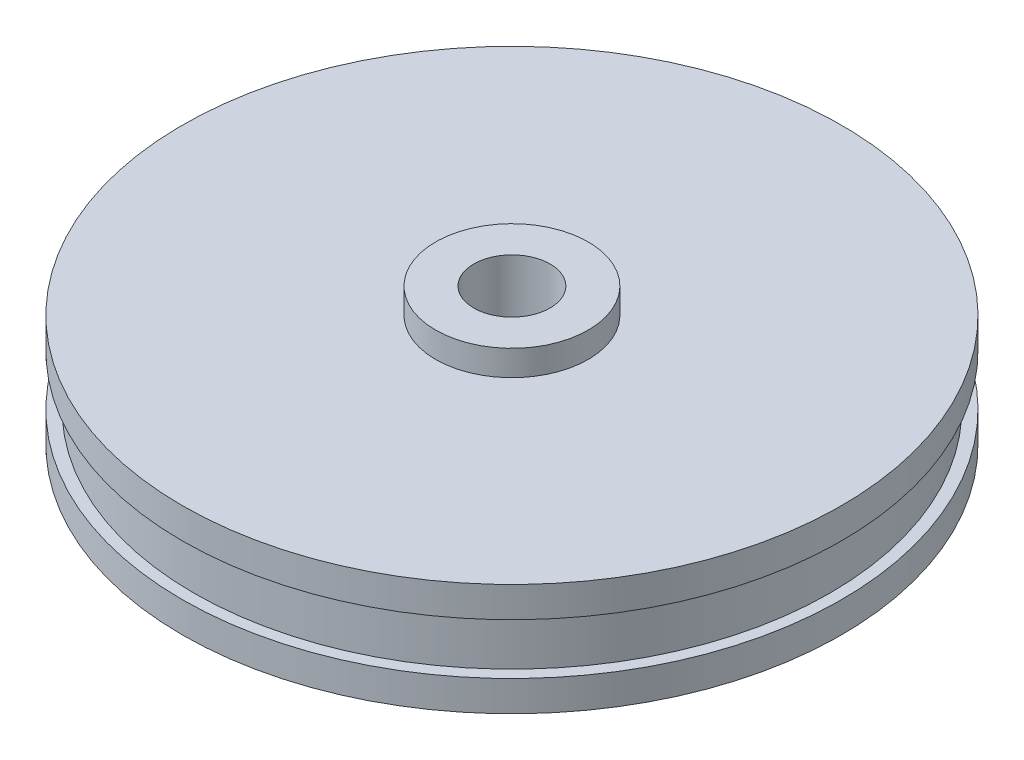
from build123d import *


with BuildPart() as part:
    # Esquisse1 → Révolution2 (revolve)
    with BuildSketch(Plane.XY):
        Polygon((12.95, -2.2), (1.5, -2.2), (1.5, 3.2), (3, 3.2), (3, 2.2), (12.95, 2.2), (12.95, 1), (12.5, 1), (12.5, -1), (12.95, -1), align=None)
    revolve(axis=Axis((0, 17.85, 0), (0, -1, 0)))


solid = part.part
